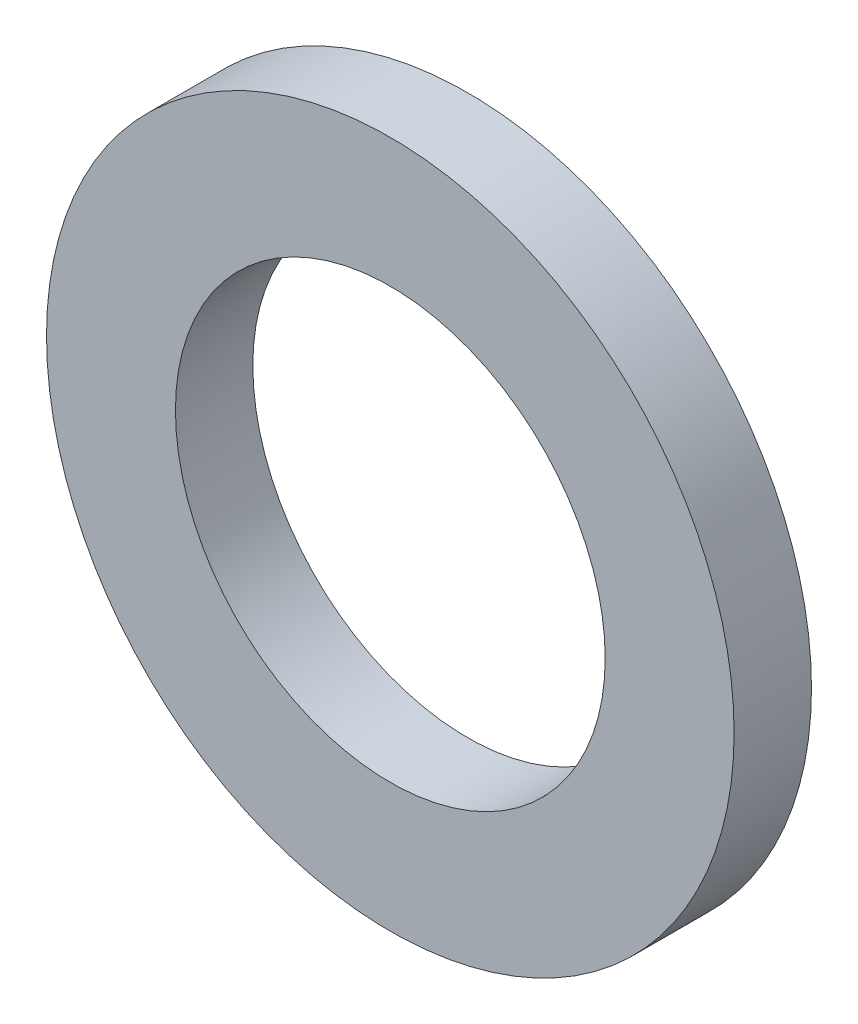
from build123d import *

# Parameters (mm, degrees)
SKETCH1_R           = 12
SKETCH1_R_2         = 7.5
BOSS_EXTRUDE1_DEPTH = 2.7


with BuildPart() as part:
    # Sketch1 → Boss-Extrude1 (new body)
    with BuildSketch(Plane.XY):
        Circle(SKETCH1_R)
        Circle(SKETCH1_R_2, mode=Mode.SUBTRACT)
    extrude(amount=BOSS_EXTRUDE1_DEPTH)


solid = part.part
